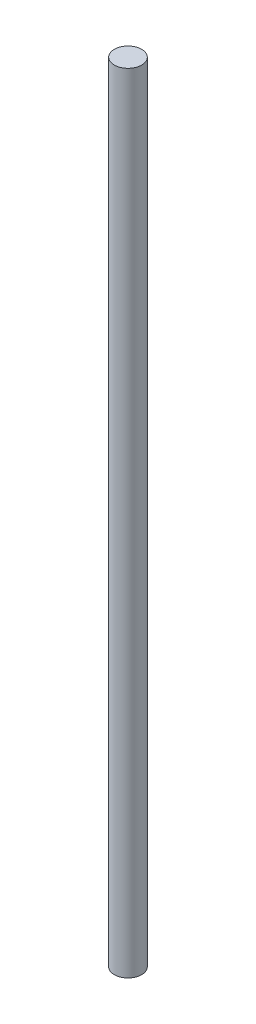
from build123d import *

# Parameters (mm, degrees)
SKETCH1_R           = 3.96875
BOSS_EXTRUDE1_DEPTH = 228.6


with BuildPart() as part:
    # Sketch1 → Boss-Extrude1 (new body)
    with BuildSketch(Plane(origin=(0, 0, 0), x_dir=(1, 0, 0), z_dir=(0, 1, 0))):
        Circle(SKETCH1_R)
    extrude(amount=BOSS_EXTRUDE1_DEPTH)


solid = part.part
